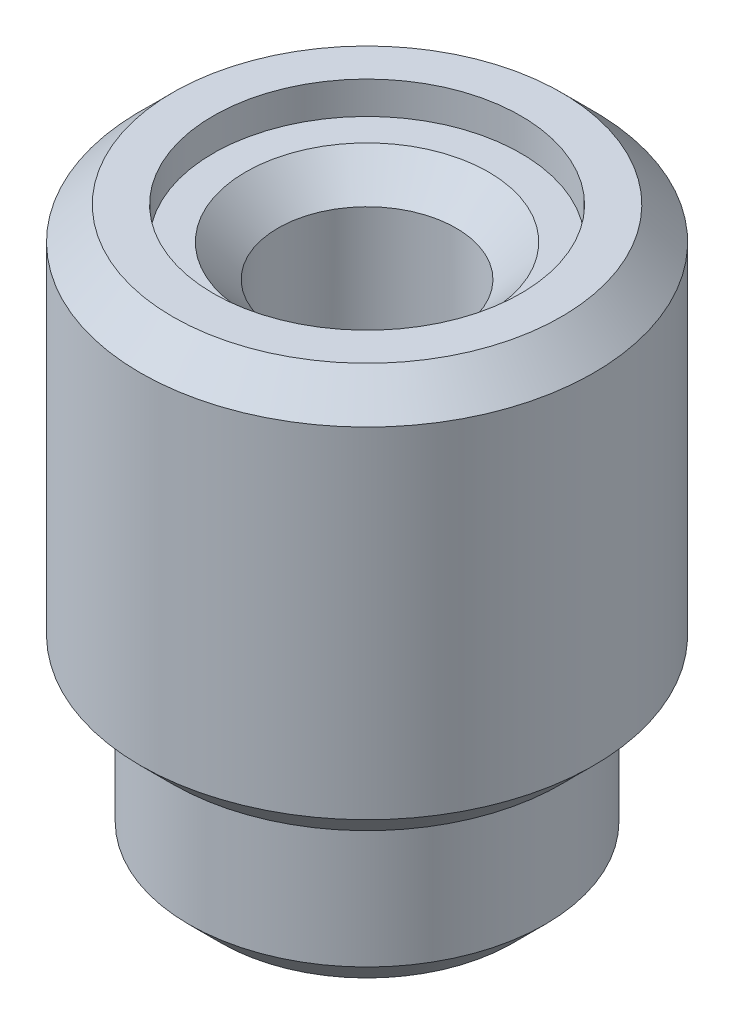
from build123d import *

# Parameters (mm, degrees)
SKETCH1_R           = 2.794
BOSS_EXTRUDE1_DEPTH = 2.54
SKETCH2_R           = 3.556
BOSS_EXTRUDE2_DEPTH = 6.35
SKETCH3_R           = 1.397
CUT_EXTRUDE1_DEPTH  = 9.89
SKETCH4_R           = 2.413
CUT_EXTRUDE2_DEPTH  = 0.508
SKETCH5_R           = 1.9939
CUT_EXTRUDE3_DEPTH  = 5.08
CHAMFER1_SIZE       = 0.508
CHAMFER2_SIZE       = 0.254
CHAMFER3_SIZE       = 0.508


with BuildPart() as part:
    # Sketch1 → Boss-Extrude1 (new body)
    with BuildSketch(Plane(origin=(0, 0, 0), x_dir=(1, 0, 0), z_dir=(0, 1, 0))):
        with Locations(Location((0, 0, 0), (0, 0, 270))):  # turned: the seam where the file's is
            Circle(SKETCH1_R)
    extrude(amount=BOSS_EXTRUDE1_DEPTH)

    # Sketch2 → Boss-Extrude2 (add)
    with BuildSketch(Plane(origin=(0, 2.54, 0), x_dir=(1, 0, 0), z_dir=(0, 1, 0))):
        with Locations(Location((0, 0, 0), (0, 0, 270))):  # turned: the seam where the file's is
            Circle(SKETCH2_R)
    extrude(amount=BOSS_EXTRUDE2_DEPTH)

    # Sketch3 → Cut-Extrude1 (cut, through all)
    with BuildSketch(Plane(origin=(0, 8.89, 0), x_dir=(1, 0, 0), z_dir=(0, 1, 0))):
        with Locations(Location((0, 0, 0), (0, 0, 270))):  # turned: the seam where the file's is
            Circle(SKETCH3_R)
    extrude(amount=-CUT_EXTRUDE1_DEPTH, mode=Mode.SUBTRACT)

    # Sketch4 → Cut-Extrude2 (cut)
    with BuildSketch(Plane(origin=(0, 8.89, 0), x_dir=(1, 0, 0), z_dir=(0, 1, 0))):
        with Locations(Location((0, 0, 0), (0, 0, 270))):  # turned: the seam where the file's is
            Circle(SKETCH4_R)
    extrude(amount=-CUT_EXTRUDE2_DEPTH, mode=Mode.SUBTRACT)

    # Sketch5 → Cut-Extrude3 (cut)
    with BuildSketch(Plane.XZ):
        with Locations(Location((0, 0, 0), (0, 0, 270))):  # turned: the seam where the file's is
            Circle(SKETCH5_R)
    extrude(amount=-CUT_EXTRUDE3_DEPTH, mode=Mode.SUBTRACT)

    # Chamfer1
    chamfer1_edges = [part.edges().sort_by_distance(p)[0] for p in [
        (0, 0, -2.794),
        (0, 2.54, -3.556),
        (0, 8.89, -3.556),
    ]]
    chamfer(chamfer1_edges, length=CHAMFER1_SIZE)

    # Chamfer2
    chamfer2_edges = [part.edges().sort_by_distance(p)[0] for p in [
        (0, 0, 1.9939),
    ]]
    chamfer(chamfer2_edges, length=CHAMFER2_SIZE)

    # Chamfer3
    chamfer3_edges = [part.edges().sort_by_distance(p)[0] for p in [
        (0, 8.382, -1.397),
    ]]
    chamfer(chamfer3_edges, length=CHAMFER3_SIZE)


solid = part.part
